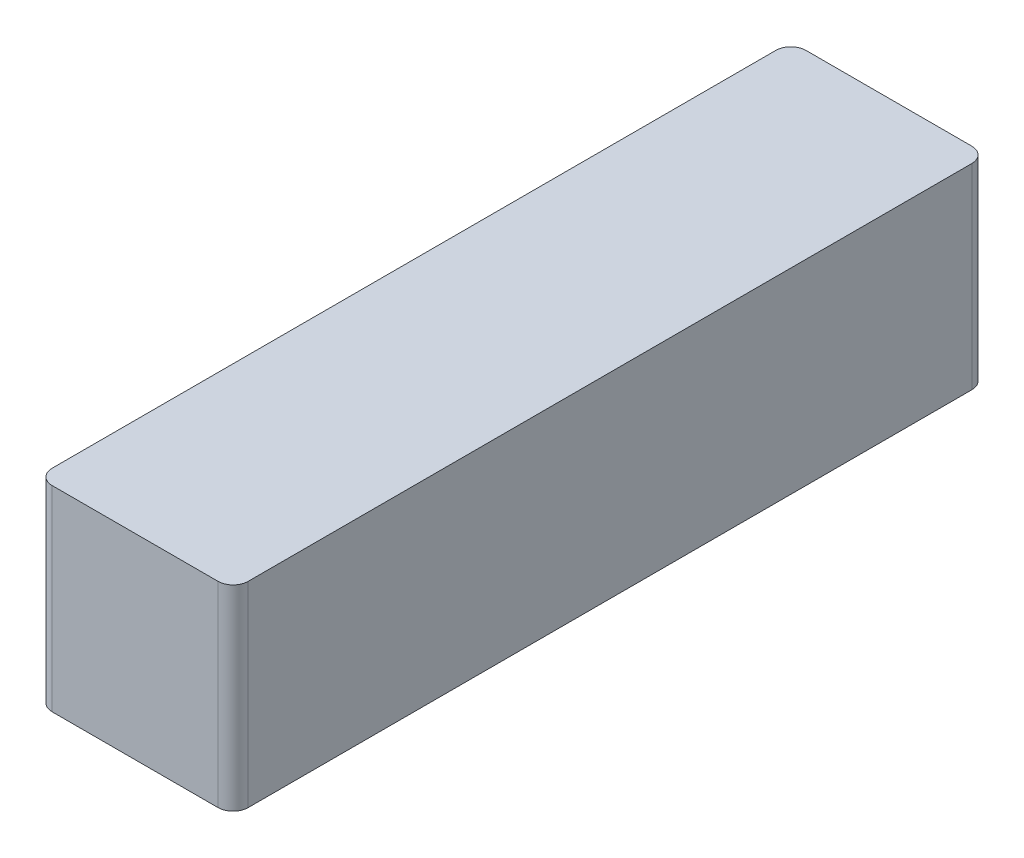
from build123d import *

# Parameters (mm, degrees)
SKETCH1_W           = 3.302
SKETCH1_H           = 3.302
BOSS_EXTRUDE1_DEPTH = 12.7
FILLET1_R           = 0.254


with BuildPart() as part:
    # Sketch1 → Boss-Extrude1 (new body)
    with BuildSketch(Plane.XY):
        Rectangle(SKETCH1_W, SKETCH1_H)
    extrude(amount=BOSS_EXTRUDE1_DEPTH)

    # Fillet1
    fillet1_edges = [part.edges().sort_by_distance(p)[0] for p in [
        (-1.651, 0, 12.7),
        (1.651, 0, 12.7),
        (-1.651, 0, 0),
        (1.651, 0, 0),
    ]]
    fillet(fillet1_edges, radius=FILLET1_R)


solid = part.part
